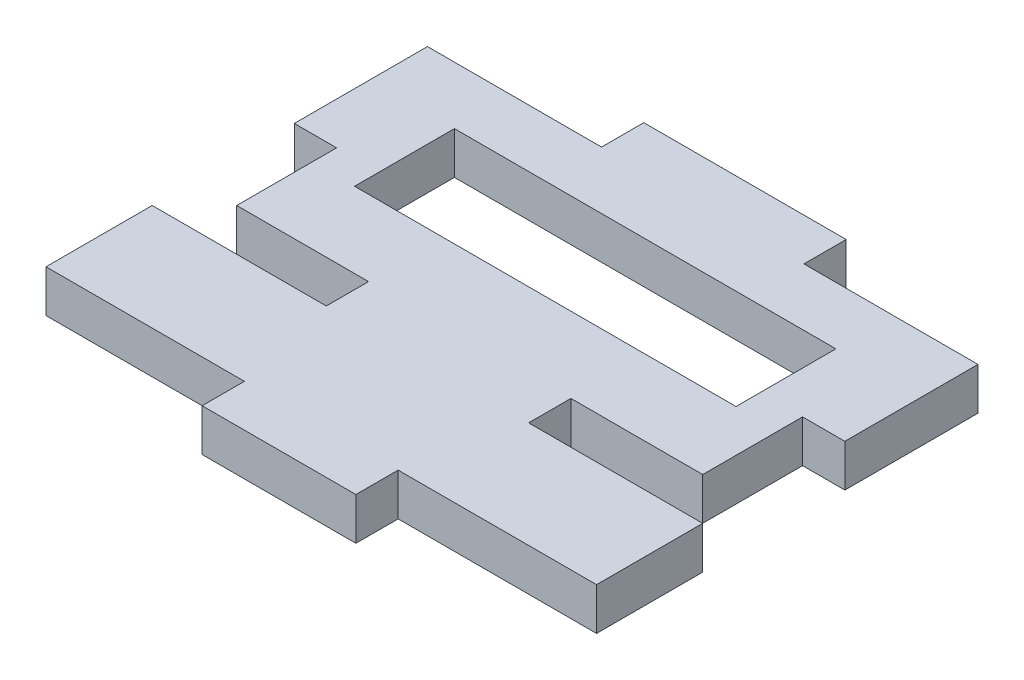
from build123d import *

# Parameters (mm, degrees)
SKETCH1_W           = 41.35
SKETCH1_H           = 35
BOSS_EXTRUDE1_DEPTH = 3.175
SKETCH2_W           = 28.65
SKETCH2_H           = 7.5
SKETCH2_W_2         = 13.075
SKETCH2_H_2         = 3.175
SKETCH2_W_3         = 14.9
CUT_EXTRUDE1_DEPTH  = 4.175


with BuildPart() as part:
    # Sketch1 → Boss-Extrude1 (new body)
    with BuildSketch(Plane(origin=(0, 0, 0), x_dir=(1, 0, 0), z_dir=(0, 1, 0))):
        with Locations((20.675, 17.5)):
            Rectangle(SKETCH1_W, SKETCH1_H)
    extrude(amount=BOSS_EXTRUDE1_DEPTH)

    # Sketch2 → Cut-Extrude1 (cut, through all)
    with BuildSketch(Plane(origin=(0, 3.175, 0), x_dir=(1, 0, 0), z_dir=(0, 1, 0))):
        with Locations((20.675, 23.75)):
            Rectangle(SKETCH2_W, SKETCH2_H)
        with Locations((6.5375, 33.4125)):
            Rectangle(SKETCH2_W_2, SKETCH2_H_2)
        with Locations((34.8125, 33.4125)):
            Rectangle(SKETCH2_W_2, SKETCH2_H_2)
        Polygon((38.175, 21.825), (41.35, 21.825), (41.35, 11.15), (28.275, 11.15), (28.275, 14.325), (38.175, 14.325), align=None)
        Polygon((3.175, 21.825), (3.175, 14.325), (13.075, 14.325), (13.075, 11.15), (0, 11.15), (0, 21.825), align=None)
        with Locations((33.9, 1.5875)):
            Rectangle(SKETCH2_W_3, SKETCH2_H_2)
        with Locations((7.45, 1.5875)):
            Rectangle(SKETCH2_W_3, SKETCH2_H_2)
    extrude(amount=-CUT_EXTRUDE1_DEPTH, mode=Mode.SUBTRACT)


solid = part.part
